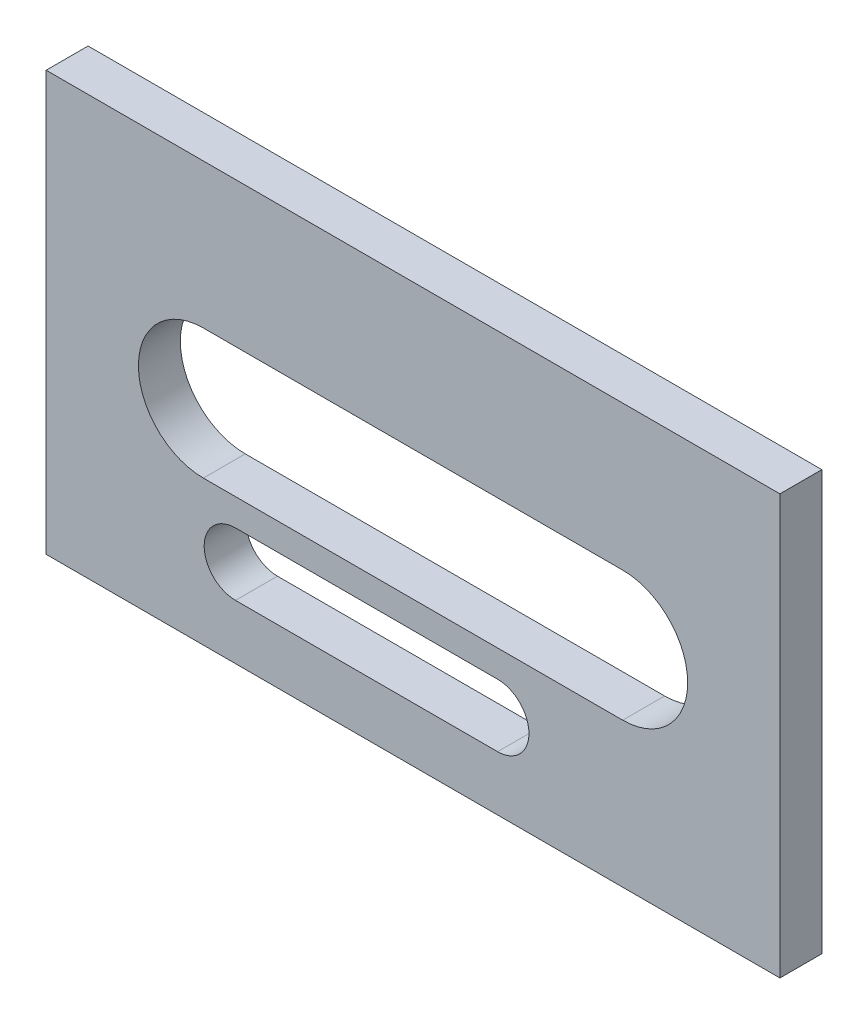
from build123d import *

# Parameters (mm, degrees)
ESQUISSE8_W        = 140
ESQUISSE8_H        = 80
BOSS_EXTRU_7_DEPTH = 8


with BuildPart() as part:
    # Esquisse8 → Boss.-Extru.7 (new body)
    with BuildSketch(Plane.XY):
        with Locations((-153.601186705, 56.489400981)):
            Rectangle(ESQUISSE8_W, ESQUISSE8_H)
        with BuildLine():
            Line((-193.601186705, 68.887436176), (-113.601186705, 68.887436176))
            ThreePointArc((-113.601186705, 68.887436176), (-101.203151511, 56.489400981), (-113.601186705, 44.091365787))
            Line((-113.601186705, 44.091365787), (-193.601186705, 44.091365787))
            ThreePointArc((-193.601186705, 44.091365787), (-205.9992219, 56.489400981), (-193.601186705, 68.887436176))
        make_face(mode=Mode.SUBTRACT)
        with BuildLine():
            Line((-187.470030447, 38.922719402), (-137.470030447, 38.922719402))
            ThreePointArc((-137.470030447, 38.922719402), (-131.485282002, 32.937970956), (-137.470030447, 26.953222511))
            Line((-137.470030447, 26.953222511), (-187.470030447, 26.953222511))
            ThreePointArc((-187.470030447, 26.953222511), (-193.454778893, 32.937970956), (-187.470030447, 38.922719402))
        make_face(mode=Mode.SUBTRACT)
    extrude(amount=BOSS_EXTRU_7_DEPTH)


solid = part.part
